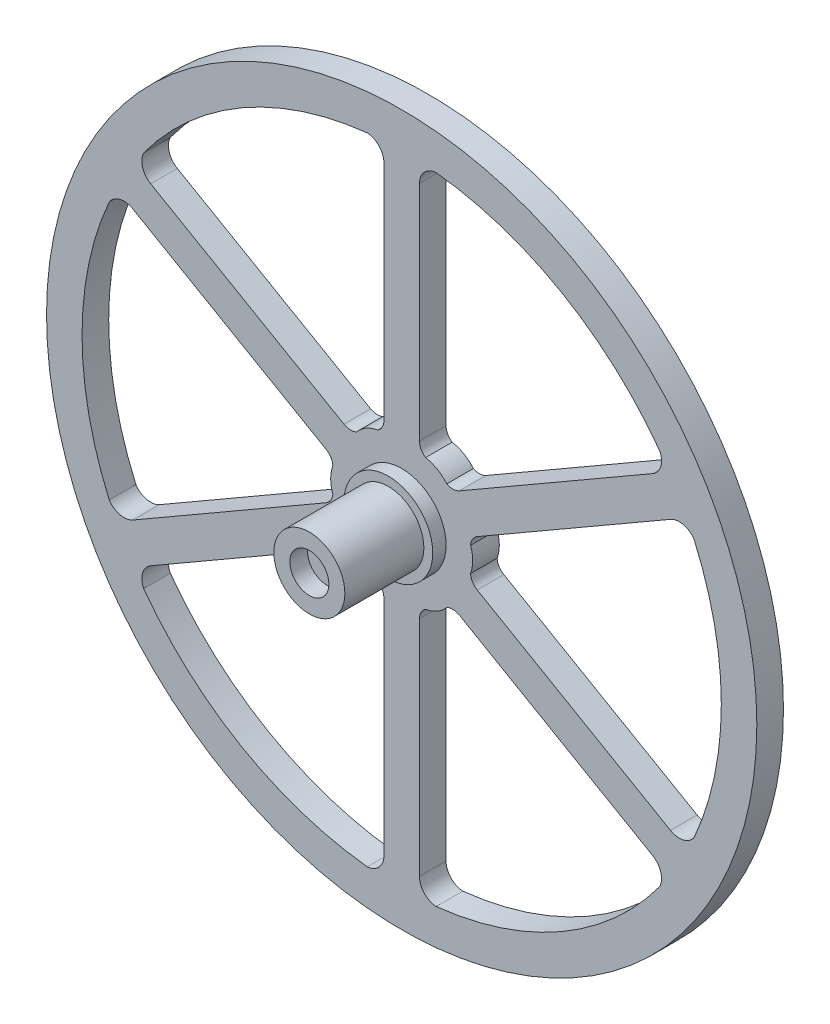
from build123d import *

# Parameters (mm, degrees)
SKETCH1_R           = 4
BOSS_EXTRUDE1_DEPTH = 8.9
SKETCH2_R           = 5
BOSS_EXTRUDE2_DEPTH = 1.5
BOSS_EXTRUDE3_START = -1.5
SKETCH3_R           = 40
BOSS_EXTRUDE3_DEPTH = 3
CUT_EXTRUDE2_START  = 8.9
SKETCH5_R           = 2.2
CUT_EXTRUDE2_DEPTH  = 2
CUT_EXTRUDE3_DEPTH  = 10


with BuildPart() as part:
    # Sketch1 → Boss-Extrude1 (new body)
    with BuildSketch(Plane.XY):
        Circle(SKETCH1_R)
    extrude(amount=BOSS_EXTRUDE1_DEPTH)

    # Sketch2 → Boss-Extrude2 (add)
    with BuildSketch(Plane.XY):
        Circle(SKETCH2_R)
    extrude(amount=-BOSS_EXTRUDE2_DEPTH)

    # Sketch3 → Boss-Extrude3 (add)
    with BuildSketch(Plane.XY.offset(BOSS_EXTRUDE3_START)):
        Circle(SKETCH3_R)
    extrude(amount=-BOSS_EXTRUDE3_DEPTH)

    # Sketch5 → Cut-Extrude2 (cut)
    with BuildSketch(Plane.XY.offset(CUT_EXTRUDE2_START)):
        Circle(SKETCH5_R)
    extrude(amount=-CUT_EXTRUDE2_DEPTH, mode=Mode.SUBTRACT)

    # Sketch6 → Cut-Extrude3 (cut)
    with BuildSketch(Plane.XY):
        with BuildLine():
            Line((30.266810214, -15.165149948), (8.5033321, -2.6))
            ThreePointArc((8.5033321, -2.6), (7.973884535, -2.083913954), (7.755291283, -1.377602039))
            ThreePointArc((7.755291283, -1.377602039), (8, 0), (7.755291283, 1.377602039))
            ThreePointArc((7.755291283, 1.377602039), (7.973884535, 2.083913954), (8.5033321, 2.6))
            Line((8.5033321, 2.6), (30.266810214, 15.165149948))
            ThreePointArc((30.266810214, 15.165149948), (31.724798793, 15.379954672), (32.934114256, 14.537679256))
            ThreePointArc((32.934114256, 14.537679256), (36, 0), (32.934114256, -14.537679256))
            ThreePointArc((32.934114256, -14.537679256), (31.724798793, -15.379954672), (30.266810214, -15.165149948))
        make_face()
        with BuildLine():
            Line((2, 33.794401511), (2, 8.664101615))
            ThreePointArc((2, 8.664101615), (2.182219844, 7.947543551), (2.684607279, 7.405080285))
            ThreePointArc((2.684607279, 7.405080285), (4, 6.92820323), (5.070684004, 6.027478245))
            ThreePointArc((5.070684004, 6.027478245), (5.791664691, 5.863629597), (6.5033321, 6.064101615))
            Line((6.5033321, 6.064101615), (28.266810214, 18.629251563))
            ThreePointArc((28.266810214, 18.629251563), (29.181830852, 19.784504349), (29.057056676, 21.252939969))
            ThreePointArc((29.057056676, 21.252939969), (18, 31.176914536), (3.87705758, 35.790619225))
            ThreePointArc((3.87705758, 35.790619225), (2.542967941, 35.164459021), (2, 33.794401511))
        make_face()
        with BuildLine():
            Line((2, -33.794401511), (2, -8.664101615))
            ThreePointArc((2, -8.664101615), (2.182219844, -7.947543551), (2.684607279, -7.405080285))
            ThreePointArc((2.684607279, -7.405080285), (4, -6.92820323), (5.070684004, -6.027478245))
            ThreePointArc((5.070684004, -6.027478245), (5.791664691, -5.863629597), (6.5033321, -6.064101615))
            Line((6.5033321, -6.064101615), (28.266810214, -18.629251563))
            ThreePointArc((28.266810214, -18.629251563), (29.181830852, -19.784504349), (29.057056676, -21.252939969))
            ThreePointArc((29.057056676, -21.252939969), (18, -31.176914536), (3.87705758, -35.790619225))
            ThreePointArc((3.87705758, -35.790619225), (2.542967941, -35.164459021), (2, -33.794401511))
        make_face()
        with BuildLine():
            Line((-28.266810214, -18.629251563), (-6.5033321, -6.064101615))
            ThreePointArc((-6.5033321, -6.064101615), (-5.791664691, -5.863629597), (-5.070684004, -6.027478245))
            ThreePointArc((-5.070684004, -6.027478245), (-4, -6.92820323), (-2.684607279, -7.405080285))
            ThreePointArc((-2.684607279, -7.405080285), (-2.182219844, -7.947543551), (-2, -8.664101615))
            Line((-2, -8.664101615), (-2, -33.794401511))
            ThreePointArc((-2, -33.794401511), (-2.542967941, -35.164459021), (-3.87705758, -35.790619225))
            ThreePointArc((-3.87705758, -35.790619225), (-18, -31.176914536), (-29.057056676, -21.252939969))
            ThreePointArc((-29.057056676, -21.252939969), (-29.181830852, -19.784504349), (-28.266810214, -18.629251563))
        make_face()
        with BuildLine():
            Line((-30.266810214, 15.165149948), (-8.5033321, 2.6))
            ThreePointArc((-8.5033321, 2.6), (-7.973884535, 2.083913954), (-7.755291283, 1.377602039))
            ThreePointArc((-7.755291283, 1.377602039), (-8, 0), (-7.755291283, -1.377602039))
            ThreePointArc((-7.755291283, -1.377602039), (-7.973884535, -2.083913954), (-8.5033321, -2.6))
            Line((-8.5033321, -2.6), (-30.266810214, -15.165149948))
            ThreePointArc((-30.266810214, -15.165149948), (-31.724798793, -15.379954672), (-32.934114256, -14.537679256))
            ThreePointArc((-32.934114256, -14.537679256), (-36, 0), (-32.934114256, 14.537679256))
            ThreePointArc((-32.934114256, 14.537679256), (-31.724798793, 15.379954672), (-30.266810214, 15.165149948))
        make_face()
        with BuildLine():
            Line((-2, 33.794401511), (-2, 8.664101615))
            ThreePointArc((-2, 8.664101615), (-2.182219844, 7.947543551), (-2.684607279, 7.405080285))
            ThreePointArc((-2.684607279, 7.405080285), (-4, 6.92820323), (-5.070684004, 6.027478245))
            ThreePointArc((-5.070684004, 6.027478245), (-5.791664691, 5.863629597), (-6.5033321, 6.064101615))
            Line((-6.5033321, 6.064101615), (-28.266810214, 18.629251563))
            ThreePointArc((-28.266810214, 18.629251563), (-29.181830852, 19.784504349), (-29.057056676, 21.252939969))
            ThreePointArc((-29.057056676, 21.252939969), (-18, 31.176914536), (-3.87705758, 35.790619225))
            ThreePointArc((-3.87705758, 35.790619225), (-2.542967941, 35.164459021), (-2, 33.794401511))
        make_face()
    extrude(amount=-CUT_EXTRUDE3_DEPTH, mode=Mode.SUBTRACT)


solid = part.part
